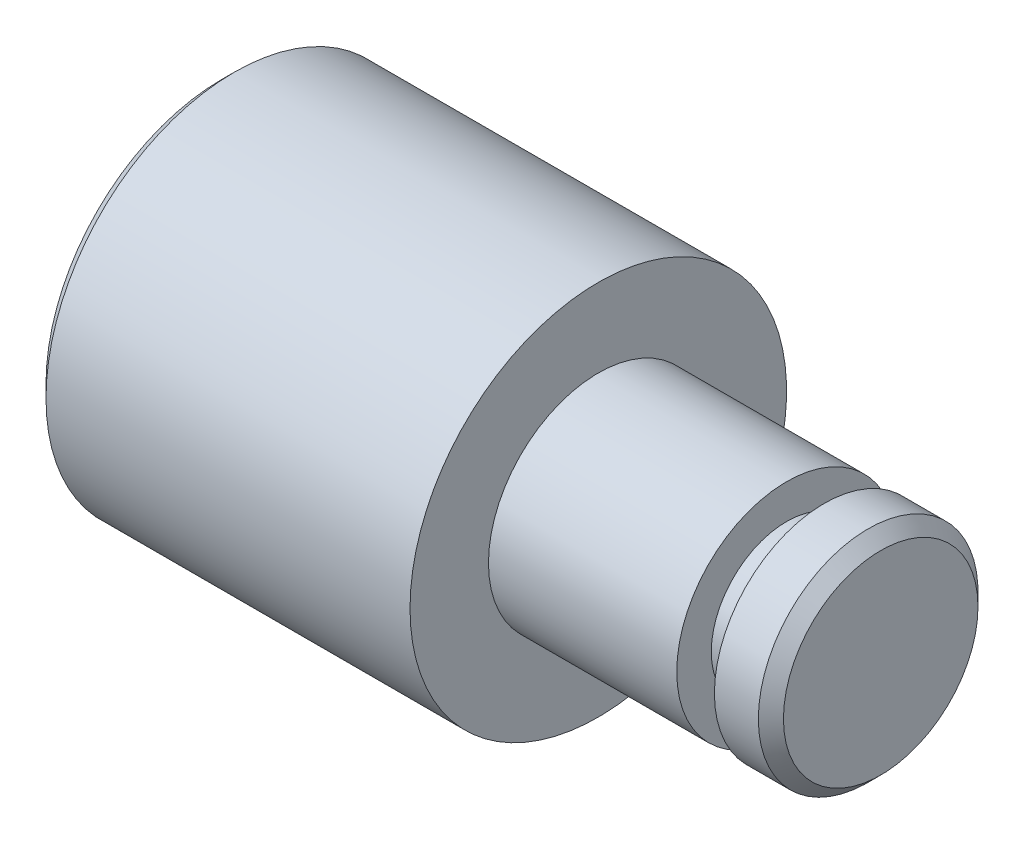
from build123d import *

# Parameters (mm, degrees)
CHANFREIN1_SIZE = 0.2


with BuildPart() as part:
    # Esquisse1 → Révolution1 (revolve)
    with BuildSketch(Plane.XY, mode=Mode.PRIVATE) as r_volution1_sk:
        Polygon((0, 0), (0, 1.75), (-0.9, 1.75), (-0.9, 1.2), (-1.5, 1.2), (-1.5, 1.75), (-4.5, 1.75), (-4.5, 3), (-10.5, 3), (-10.5, 0), align=None)
    revolve(r_volution1_sk.sketch.rotate(Axis((0, 0, 0), (1, 0, 0)), 90), axis=Axis((0, 0, 0), (1, 0, 0)))  # turned: the seam where the file's is

    # Chanfrein1
    chanfrein1_edges = [part.edges().sort_by_distance(p)[0] for p in [
        (-10.5, 0, -3),
        (0, 0, -1.75),
    ]]
    chamfer(chanfrein1_edges, length=CHANFREIN1_SIZE)


solid = part.part
